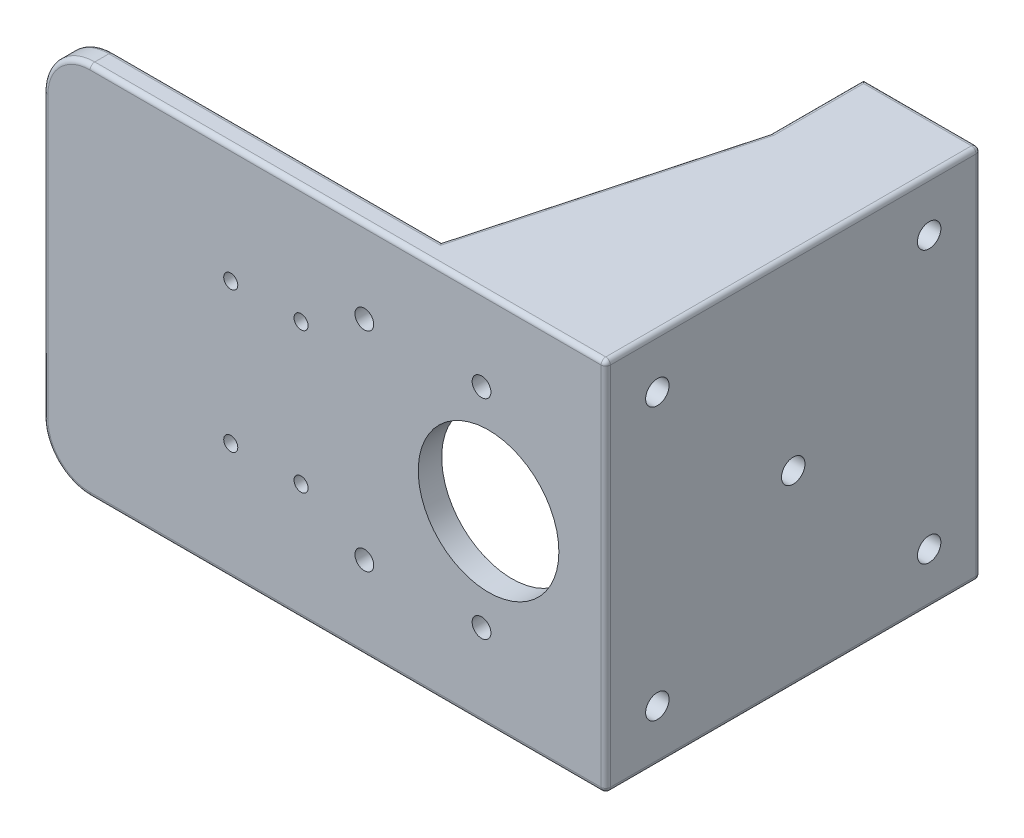
from build123d import *

# Parameters (mm, degrees)
SKETCH_1_W               = 120
SKETCH_1_H               = 80
EXTRUDE_1_DEPTH          = 5
SKETCH_3_R               = 4
CUT_EXTRUDE_2_DEPTH      = 10
SKETCH_5_R               = 15
CUT_EXTRUDE_3_DEPTH      = 10
F_4_0MM_1_D              = 4
FILLET_1_R               = 10
SKETCH_13_R              = 6.969385005
EXTRUDE_5_DEPTH          = 5
SKETCH_14_W              = 5
SKETCH_14_H              = 75
EXTRUDE_6_DEPTH          = 80
SKETCH_15_W              = 20
SKETCH_15_H              = 5
EXTRUDE_7_DEPTH          = 80
EXTRUDE_8_DEPTH          = 5
FILLET_2_R               = 1
F_3_0MM_1_D              = 3
F_3_0MM_1_DEPTH          = 7.5
F_3_0MM_1_TIP            = 0.901290929
SKETCH_21_R              = 2.5
CUT_EXTRUDE_7_DEPTH      = 10
PATTERN_CIRCULAR_1_COUNT = 4


with BuildPart() as part:
    # 草图1 → 凸台-拉伸1 (new body)
    with BuildSketch(Plane.XY):
        Rectangle(SKETCH_1_W, SKETCH_1_H)
    extrude(amount=EXTRUDE_1_DEPTH)

    # 草图3 → 切除-拉伸2 (cut)
    with BuildSketch(Plane.XY.offset(5)):
        with Locations((-45, 0)):
            Circle(SKETCH_3_R)
    extrude(amount=-CUT_EXTRUDE_2_DEPTH, mode=Mode.SUBTRACT)

    # 草图5 → 切除-拉伸3 (cut)
    with BuildSketch(Plane.XY.offset(5)):
        with Locations((35, 0)):
            Circle(SKETCH_5_R)
    extrude(amount=-CUT_EXTRUDE_3_DEPTH, mode=Mode.SUBTRACT)

    # Ø4.0mm 暗销孔1 (through all)
    with Locations(Plane(origin=(0, 0, 0), x_dir=(-1, 0, 0), z_dir=(0, 0, -1))):
        with Locations((-8.5, -22.25), (-8.5, 22.25), (-33.5, 22.25), (-33.5, -22.25)):
            Hole(F_4_0MM_1_D / 2)

    # 圆角1
    fillet_1_edges = [part.edges().sort_by_distance(p)[0] for p in [
        (-60, 40, 2.5),
        (-60, -40, 2.5),
    ]]
    fillet(fillet_1_edges, radius=FILLET_1_R)

    # 草图13 → 凸台-拉伸5 (add)
    with BuildSketch(Plane.XY.offset(5)):
        with Locations((-45, 0)):
            Circle(SKETCH_13_R)
    extrude(amount=-EXTRUDE_5_DEPTH)

    # 草图14 → 凸台-拉伸6 (add)
    with BuildSketch(Plane.XZ.offset(40)):
        with Locations((57.5, -37.5)):
            Rectangle(SKETCH_14_W, SKETCH_14_H)
    extrude(amount=-EXTRUDE_6_DEPTH)

    # 草图15 → 凸台-拉伸7 (add)
    with BuildSketch(Plane.XZ.offset(40)):
        with Locations((45, -72.5)):
            Rectangle(SKETCH_15_W, SKETCH_15_H)
    extrude(amount=-EXTRUDE_7_DEPTH)

    # 草图16 → 凸台-拉伸8 (add)
    with BuildSketch(Plane.XZ.offset(40)):
        Polygon((20, 5), (20, 0), (35, -55), (35, -75), (60, -75), (60, 5), align=None)
    extrude_8 = extrude(amount=-EXTRUDE_8_DEPTH)

    # 镜向1: 凸台-拉伸8 across plane
    add(extrude_8.mirror(Plane.ZX))

    # 圆角2
    fillet_2_edges = [part.edges().sort_by_distance(p)[0] for p in [
        (27.5, -40, -27.5),
        (-15, 40, 0),
        (60, 0, 5),
        (27.5, 40, -27.5),
        (5, 40, 5),
        (-15, -40, 0),
        (5, -40, 5),
        (-60, 0, 0),
        (-57.071067812, 37.071067812, 0),
        (-57.071067812, -37.071067812, 0),
        (-60, 0, 5),
        (-57.071067812, 37.071067812, 5),
        (-57.071067812, -37.071067812, 5),
        (60, 0, -75),
        (47.5, -40, -75),
        (47.5, 40, -75),
        (60, 40, -35),
        (60, -40, -35),
        (35, -40, -65),
        (35, 40, -65),
    ]]
    fillet(fillet_2_edges, radius=FILLET_2_R)

    # Ø3.0mm 暗销孔1
    with Locations(Plane.XY.offset(5)):
        with Locations((-5, -15), (-5, 15), (-20, 15), (-20, -15)):
            Hole(F_3_0MM_1_D / 2, depth=F_3_0MM_1_DEPTH)
            with Locations((0, 0, -(F_3_0MM_1_DEPTH + F_3_0MM_1_TIP / 2))):  # 118° drill point
                Cone(0, F_3_0MM_1_D / 2, F_3_0MM_1_TIP, mode=Mode.SUBTRACT)

    # 草图21 → 切除-拉伸7 (cut)
    with BuildSketch(Plane(origin=(60, 0, 0), x_dir=(0, 0, -1), z_dir=(1, 0, 0))):
        with Locations((35, 0)):
            Circle(SKETCH_21_R)
    extrude(amount=-CUT_EXTRUDE_7_DEPTH, mode=Mode.SUBTRACT)

    # 草图24 → Ø5.0mm 暗销孔1 (revolve, cut)
    with BuildSketch(Plane(origin=(60, 28.991378029, -6.008621971), x_dir=(0, 0, -1), z_dir=(0, 1, 0))):
        Polygon((0, 0), (0, 13.902151548), (2.5, 12.4), (2.5, 0), align=None)
    f_5_0mm_1 = revolve(axis=Axis((66.35, 28.991378029, -6.008621971), (-1, 0, 0)), mode=Mode.SUBTRACT)

    # 阵列(圆周)1: Ø5.0mm 暗销孔1 ×4 about axis
    pattern_circular_1_axis = Axis((0, 0, -35), (1, 0, 0))
    for i in range(1, PATTERN_CIRCULAR_1_COUNT):
        add(f_5_0mm_1.rotate(pattern_circular_1_axis, i * 360 / PATTERN_CIRCULAR_1_COUNT), mode=Mode.SUBTRACT)


solid = part.part
